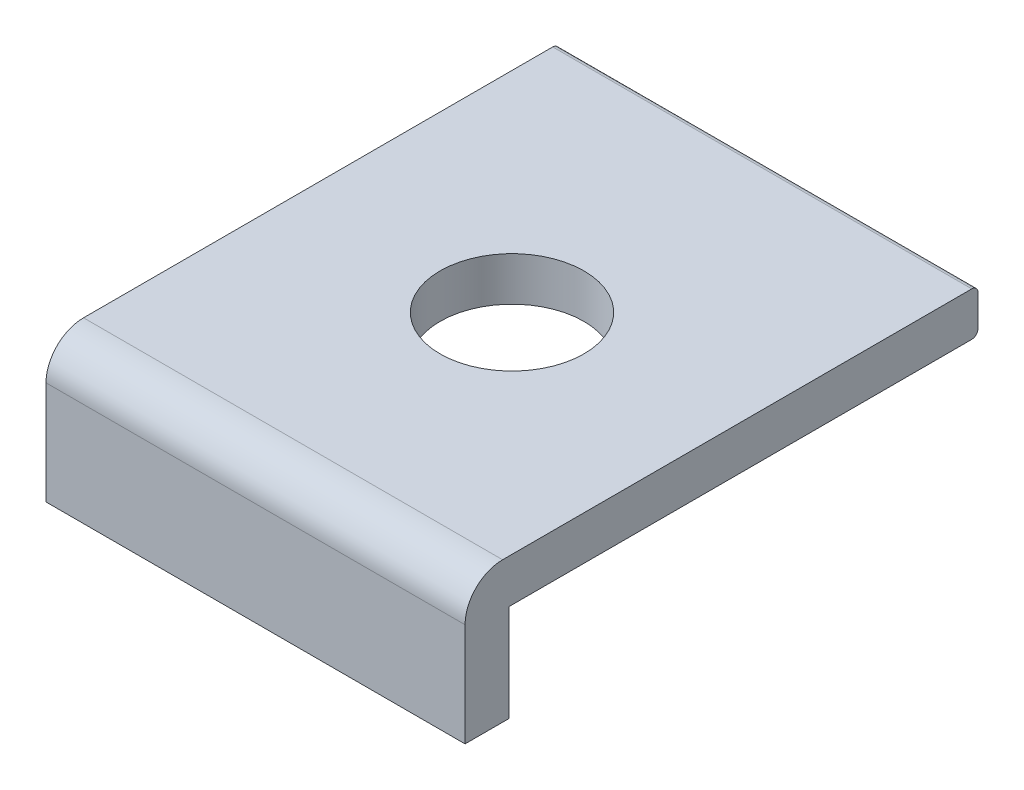
from build123d import *

# Parameters (mm, degrees)
RESSALTO_EXTRUS_O12_DEPTH = 6.7
ESBO_O7_R                 = 1.15
CORTE_EXTRUS_O3_DEPTH     = 6.7


with BuildPart() as part:
    # Esboço4 → Ressalto-extrusão12 (new body)
    with BuildSketch(Plane(origin=(0, 0, 0), x_dir=(0, 0, -1), z_dir=(1, 0, 0))):
        with BuildLine():
            Line((0, 0), (0, 1.65))
            ThreePointArc((0, 1.65), (0.175735931, 2.074264069), (0.6, 2.25))
            Line((0.6, 2.25), (8.101, 2.25))
            ThreePointArc((8.101, 2.25), (8.171710678, 2.220710678), (8.201, 2.15))
            Line((8.201, 2.15), (8.201, 1.65))
            ThreePointArc((8.201, 1.65), (8.171710678, 1.579289322), (8.101, 1.55))
            Line((8.101, 1.55), (0.7, 1.55))
            Line((0.7, 1.55), (0.7, 0))
            Line((0.7, 0), (0, 0))
        make_face()
    extrude(amount=RESSALTO_EXTRUS_O12_DEPTH)

    # Esboço7 → Corte-extrusão3 (cut)
    with BuildSketch(Plane(origin=(0, 2.25, 0), x_dir=(1, 0, 0), z_dir=(0, 1, 0))):
        with Locations((3.35, 4.1005)):
            Circle(ESBO_O7_R)
    extrude(amount=-CORTE_EXTRUS_O3_DEPTH, mode=Mode.SUBTRACT)


solid = part.part
